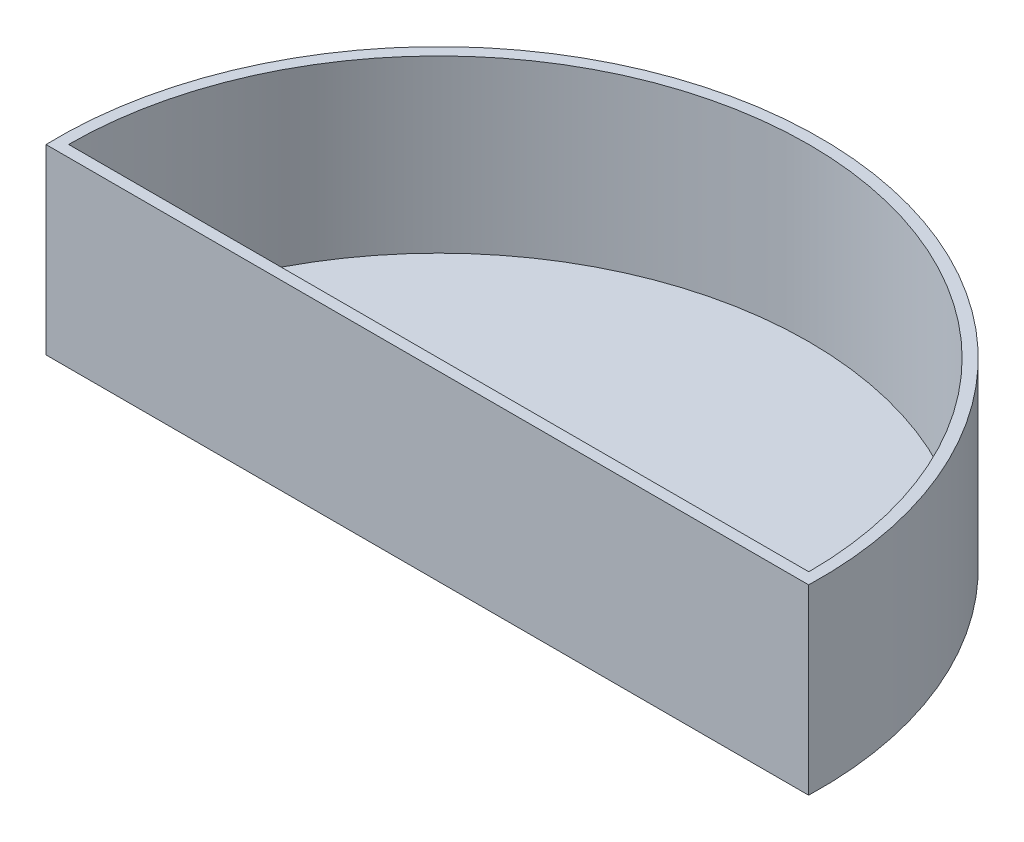
from build123d import *

# Parameters (mm, degrees)
BOSS_EXTRUDE2_DEPTH = 6
BOSS_EXTRUDE3_DEPTH = 0.4


with BuildPart() as part:
    # Sketch3 → Boss-Extrude2 (new body)
    with BuildSketch(Plane(origin=(0, 0, 0), x_dir=(1, 0, 0), z_dir=(0, 1, 0))):
        with BuildLine():
            Line((-13.39402852, -0.4), (13.39402852, -0.4))
            ThreePointArc((13.39402852, -0.4), (0, 13.4), (-13.39402852, -0.4))
        make_face()
        with BuildLine():
            Line((-13, 0), (13, 0))
            ThreePointArc((13, 0), (0, 13), (-13, 0))
        make_face(mode=Mode.SUBTRACT)
    extrude(amount=BOSS_EXTRUDE2_DEPTH)

    # Sketch4 → Boss-Extrude3 (add)
    with BuildSketch(Plane.XZ):
        with BuildLine():
            Line((-13.39402852, 0.4), (13.39402852, 0.4))
            ThreePointArc((13.39402852, 0.4), (0, -13.4), (-13.39402852, 0.4))
        make_face()
    extrude(amount=BOSS_EXTRUDE3_DEPTH)


solid = part.part
